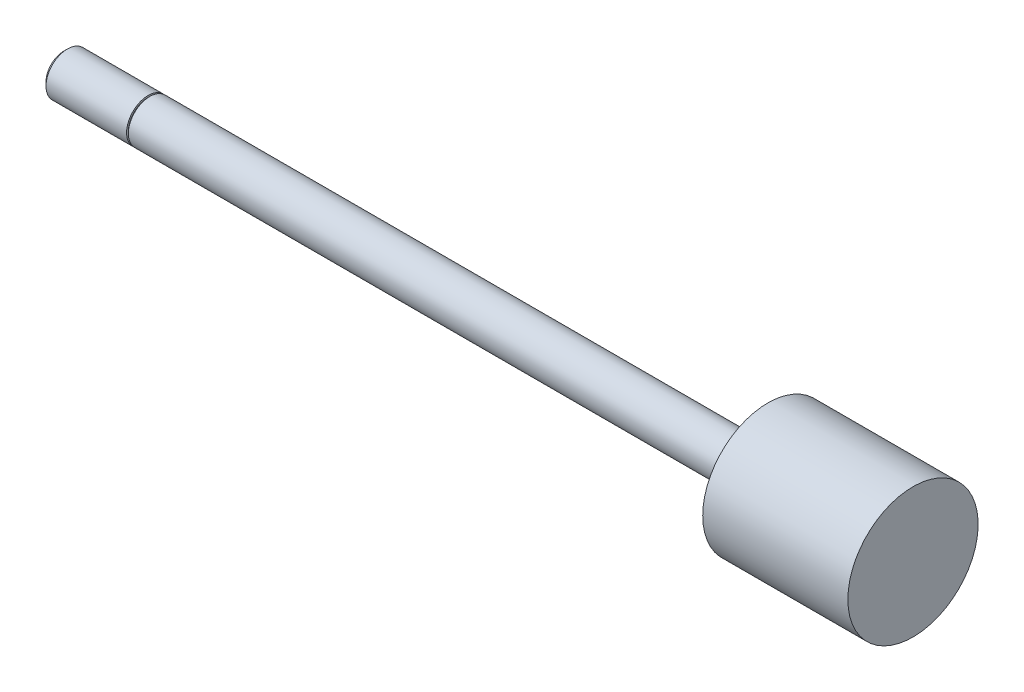
from build123d import *

# Parameters (mm, degrees)
SKETCH3_W = 0.254
SKETCH3_H = 0.508


with BuildPart() as part:
    # Sketch1 → Revolve1 (revolve)
    with BuildSketch(Plane.XY):
        Polygon((0, 0), (0, 3.175), (91.2876, 3.175), (91.2876, 9.62025), (112.7252, 9.62025), (112.7252, 0), align=None)
    revolve(axis=Axis((112.7252, 0, 0), (-1, 0, 0)))

    # Sketch2 → Revolve2 (revolve)
    with BuildSketch(Plane.XY):
        Polygon((-12.7, 0), (-12.7, 2.63398), (-12.15898, 3.175), (0, 3.175), (0, 0), align=None)
    revolve(axis=Axis((0, 0, 0), (-1, 0, 0)))

    # Sketch3 → Cut-Revolve1 (revolve, cut)
    with BuildSketch(Plane.XY):
        with Locations((-0.127, 3.175)):
            Rectangle(SKETCH3_W, SKETCH3_H)
    revolve(axis=Axis((0, 0, 0), (-1, 0, 0)), mode=Mode.SUBTRACT)


solid = part.part
